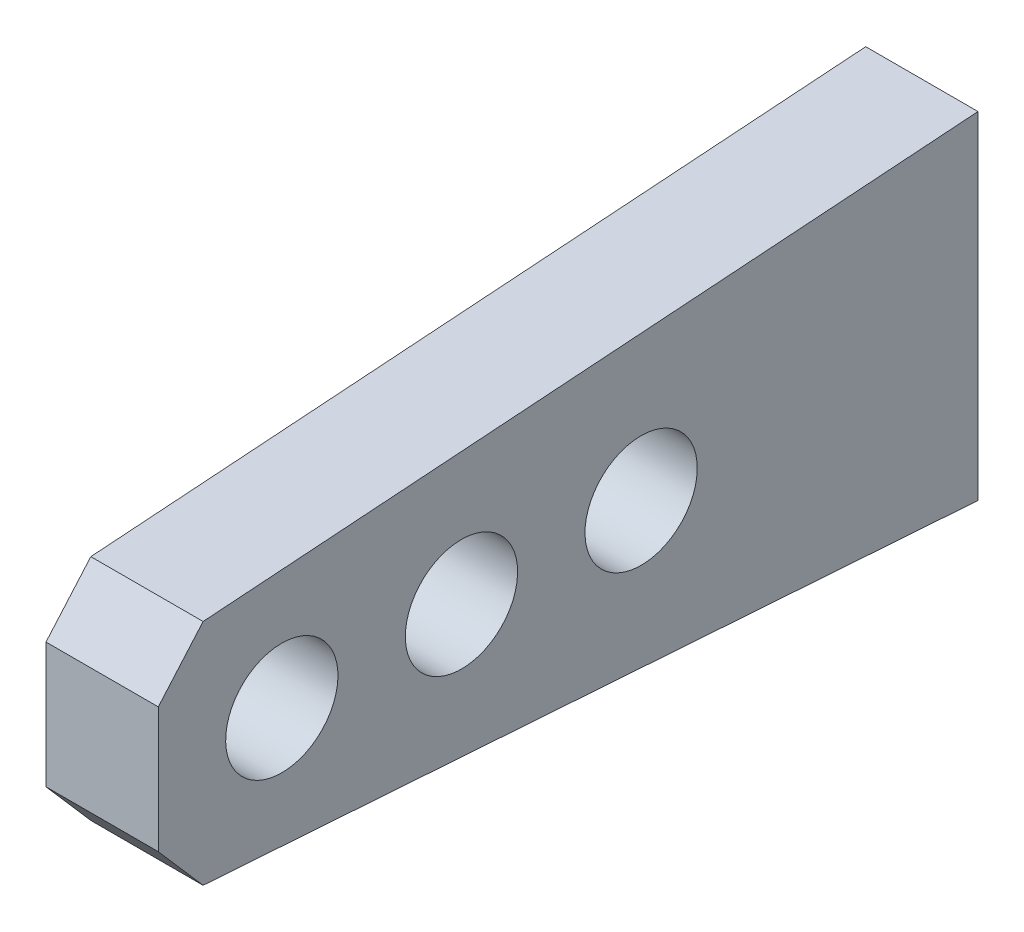
from build123d import *

# Parameters (mm, degrees)
ESBO_O1_W                = 1
ESBO_O1_H                = 3
RESSALTO_EXTRUS_O1_DEPTH = 7.3
INCLINA_O2_ANGLE         = -4
CHANFRO1_SIZE2           = 0.431123878
CHANFRO1_SIZE            = 0.4
CHANFRO1_EDGE_2_SIZE2    = 0.4
CHANFRO1_EDGE_2_SIZE     = 0.431123878
ESBO_O2_R                = 0.5
CORTE_EXTRUS_O1_DEPTH    = 1


with BuildPart() as part:
    # Esboço1 → Ressalto-extrusão1 (new body)
    with BuildSketch(Plane.XY):
        Rectangle(ESBO_O1_W, ESBO_O1_H)
    extrude(amount=RESSALTO_EXTRUS_O1_DEPTH)

    # Inclinação2
    inclina_o2_faces = [part.faces().sort_by_distance(p)[0] for p in [
        (0, 1.5, 3.65),
        (0, -1.5, 3.65),
    ]]
    draft(inclina_o2_faces, Plane(origin=(0, 0, 0), x_dir=(-1, 0, 0), z_dir=(0, 0, -1)), INCLINA_O2_ANGLE)

    # Chanfro1
    chanfro1_edges = [part.edges().sort_by_distance(p)[0] for p in [
        (0, -0.989534273, 7.3),
    ]]
    chamfer(chanfro1_edges, length=CHANFRO1_SIZE, length2=CHANFRO1_SIZE2)

    # Chanfro1 edge 2
    chanfro1_edge_2_edges = [part.edges().sort_by_distance(p)[0] for p in [
        (0, 0.989534273, 7.3),
    ]]
    chamfer(chanfro1_edge_2_edges, length=CHANFRO1_EDGE_2_SIZE, length2=CHANFRO1_EDGE_2_SIZE2)

    # Esboço2 → Corte-extrusão1 (cut)
    with BuildSketch(Plane(origin=(0.5, 0, 0), x_dir=(0, 0, -1), z_dir=(1, 0, 0))):
        with Locations((-6.2, 0)):
            Circle(ESBO_O2_R)
        with Locations((-4.6, 0)):
            Circle(ESBO_O2_R)
        with Locations((-3, 0)):
            Circle(ESBO_O2_R)
    extrude(amount=-CORTE_EXTRUS_O1_DEPTH, mode=Mode.SUBTRACT)


solid = part.part
